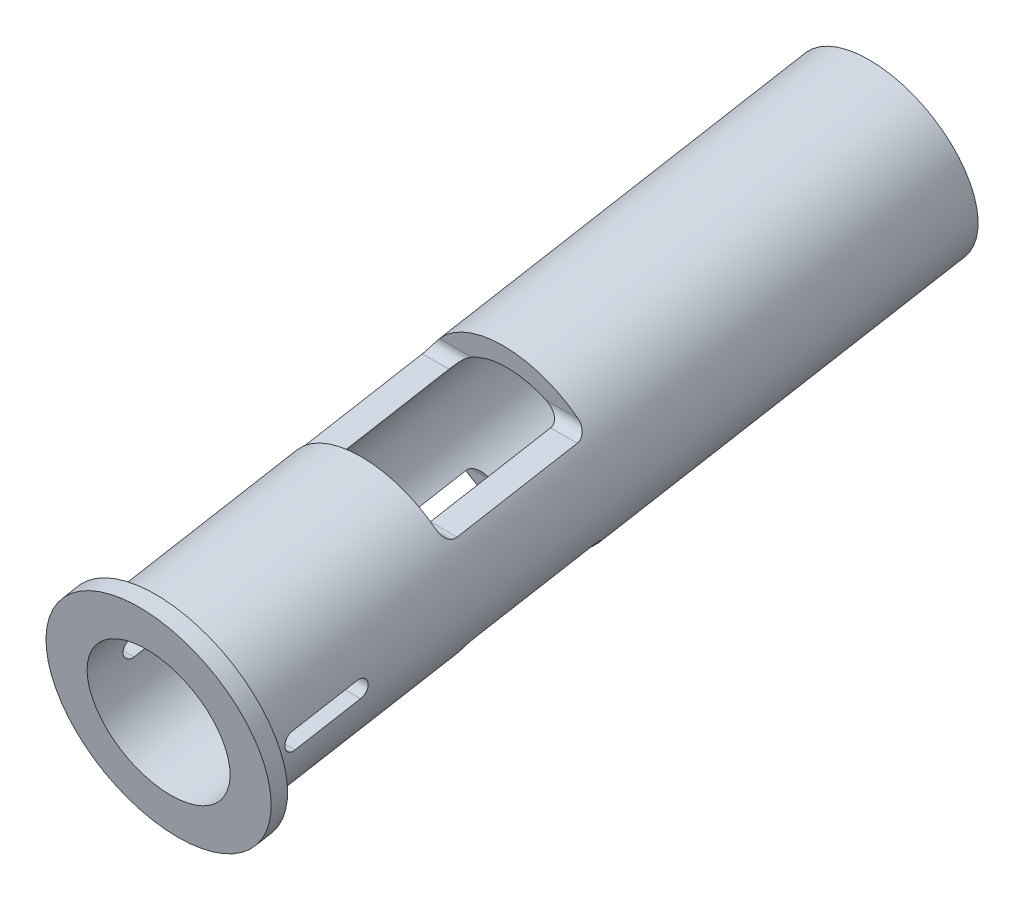
from build123d import *

# Parameters (mm, degrees)
BOSS_EXTRUDE1_DEPTH     = 25
FILLET1_R               = 2
CUT_EXTRUDE1_DEPTH      = 171.565921027
CUT_EXTRUDE1_DEPTH_BACK = 171.565921027
SKETCH4_R               = 20
SKETCH4_R_2             = 16.5
SKETCH4_R_3             = 12.7
BOSS_EXTRUDE2_DEPTH     = 3


with BuildPart() as part:
    # Sketch1 → Revolve1 (revolve)
    with BuildSketch(Plane(origin=(0, 0, 0), x_dir=(0, 0, -1), z_dir=(1, 0, 0)), mode=Mode.PRIVATE) as revolve1_sk:
        Polygon((112.672204387, 118.557087119), (-15.352803504, 95.982824023), (-16.01266658, 99.725093484), (112.012341312, 122.299356581), align=None)
    revolve(revolve1_sk.sketch.rotate(Axis((0, 83.475765559, 13.147471648), (0, 0.17364817766692353, -0.9848077530122092)), 180), axis=Axis((0, 83.475765559, 13.147471648), (0, 0.17364817766692353, -0.9848077530122092)))


with BuildPart() as body_2:
    # Sketch2 → Boss-Extrude1 (new, symmetric)
    with BuildSketch(Plane(origin=(0, 0, 0), x_dir=(0, 0, -1), z_dir=(1, 0, 0))):
        Polygon((20.025829473, 108.41513389), (21.76231125, 98.56705636), (47.367312828, 103.081908979), (45.630831052, 112.929986509), align=None)
    extrude(amount=BOSS_EXTRUDE1_DEPTH, both=True)


with BuildPart() as body_3:
    # Mirror1: mirrored copy
    add(body_2.part.mirror(Plane(origin=(0, 83.207013304, 14.67164143), x_dir=(0, -0.17364817766692353, 0.9848077530122092), z_dir=(0, -0.9848077530122092, -0.17364817766692353))))


with BuildPart() as part_1:
    add(part.part)

    # Combine2: cut body 2, body 3
    add(body_2.part, mode=Mode.SUBTRACT)
    add(body_3.part, mode=Mode.SUBTRACT)

    # Fillet1
    fillet1_edges = [part_1.edges().sort_by_distance(p)[0] for p in [
        (-11.557199929, 98.56705636, -21.76231125),
        (11.557199929, 98.56705636, -21.76231125),
        (-11.557199929, 103.081908979, -47.367312828),
        (11.557199929, 103.081908979, -47.367312828),
        (-11.557199929, 81.234439907, -24.818519177),
        (11.557199929, 81.234439907, -24.818519177),
        (11.557199929, 85.749292526, -50.423520755),
        (-11.557199929, 85.749292526, -50.423520755),
    ]]
    fillet(fillet1_edges, radius=FILLET1_R)

    # Sketch3 → Cut-Extrude1 (cut, two sides)
    with BuildSketch(Plane(origin=(0, 0, 0), x_dir=(0, 0, -1), z_dir=(1, 0, 0))) as cut_extrude1_sk:
        with BuildLine():
            Line((-8.501269967, 85.919698853), (3.316423069, 88.003476985))
            ThreePointArc((3.316423069, 88.003476985), (5.169952558, 86.705621664), (3.872097237, 84.852092175))
            Line((3.872097237, 84.852092175), (-7.945595799, 82.768314043))
            ThreePointArc((-7.945595799, 82.768314043), (-9.799125288, 84.066169363), (-8.501269967, 85.919698853))
        make_face()
    extrude(amount=CUT_EXTRUDE1_DEPTH, mode=Mode.SUBTRACT)
    extrude(cut_extrude1_sk.sketch, amount=-CUT_EXTRUDE1_DEPTH_BACK, mode=Mode.SUBTRACT)

    # Sketch4 → Boss-Extrude2 (add)
    with BuildSketch(Plane(origin=(0, 0.268752256, -1.524169782), x_dir=(1, 0, 0), z_dir=(0, -0.17364817766692353, 0.9848077530122092))):
        with Locations(Location((0, 84.490615604, 0), (0, 0, 270))):
            Circle(SKETCH4_R)
        with Locations(Location((0, 84.490615604, 0), (0, 0, 270))):
            Circle(SKETCH4_R_2, mode=Mode.SUBTRACT)
        with Locations(Location((0, 84.490615604, 0), (0, 0, 270))):
            Circle(SKETCH4_R_2)
        with Locations(Location((0, 84.490615604, 0), (0, 0, 270))):
            Circle(SKETCH4_R_3, mode=Mode.SUBTRACT)
    extrude(amount=BOSS_EXTRUDE2_DEPTH)


solid = part_1.part
